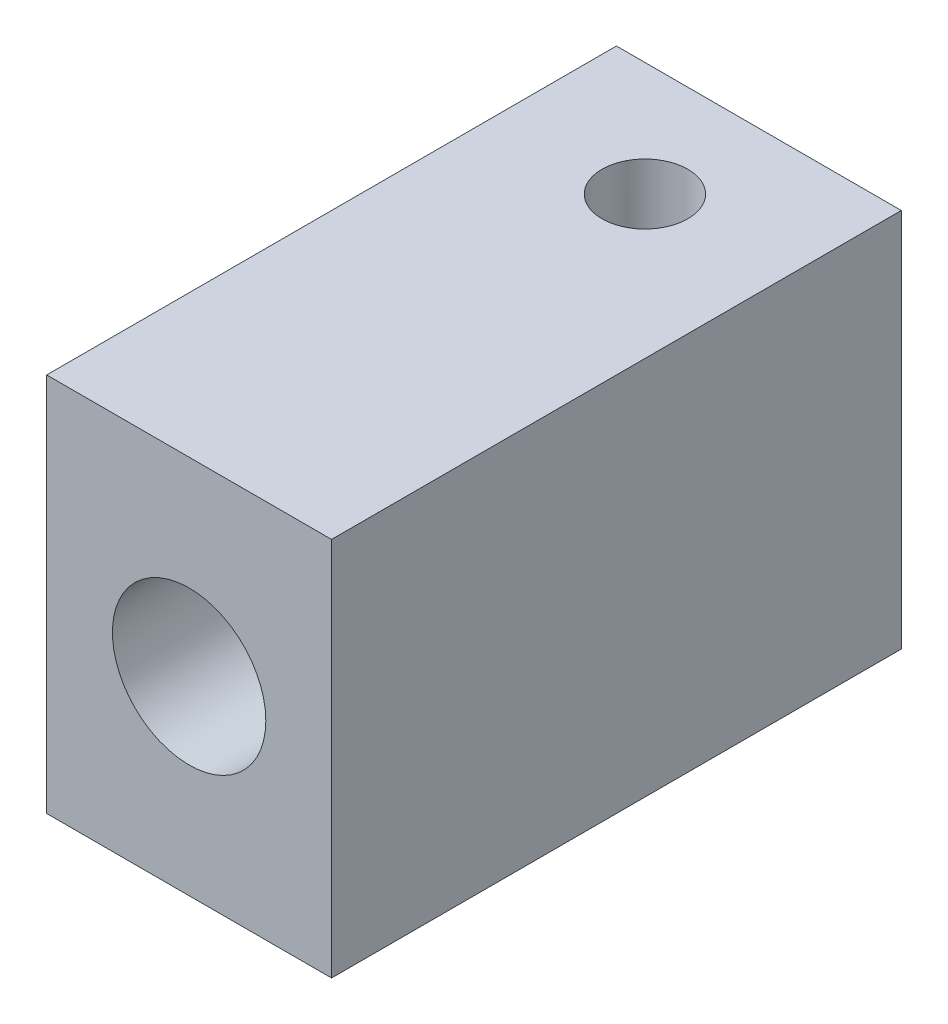
from build123d import *

# Parameters (mm, degrees)
SKETCH1_W                     = 7.5
SKETCH1_H                     = 10
BOSS_EXTRUDE1_DEPTH           = 15
HOLE_FOR_TUBING_R             = 1.1
CUT_EXTRUDE1_DEPTH            = 16
F_10_32_HOLE_FOR_LUER_SCREW_R = 2.0193
CUT_EXTRUDE2_DEPTH            = 7.5
F_4_40_SET_SCREW_HOLE_R       = 1.1303
CUT_EXTRUDE3_DEPTH            = 11


with BuildPart() as part:
    # Sketch1 → Boss-Extrude1 (new body)
    with BuildSketch(Plane.XY):
        with Locations((-4.663043478, 2.239130435)):
            Rectangle(SKETCH1_W, SKETCH1_H)
    extrude(amount=BOSS_EXTRUDE1_DEPTH)

    # hole for tubing → Cut-Extrude1 (cut, through all)
    with BuildSketch(Plane(origin=(0, 0, 0), x_dir=(-1, 0, 0), z_dir=(0, 0, -1))):
        with Locations((4.663043478, 2.239130435)):
            Circle(HOLE_FOR_TUBING_R)
    extrude(amount=-CUT_EXTRUDE1_DEPTH, mode=Mode.SUBTRACT)

    # 10-32 hole for luer screw → Cut-Extrude2 (cut)
    with BuildSketch(Plane.XY.offset(15)):
        with Locations((-4.663043478, 2.239130435)):
            Circle(F_10_32_HOLE_FOR_LUER_SCREW_R)
    extrude(amount=-CUT_EXTRUDE2_DEPTH, mode=Mode.SUBTRACT)

    # 4-40 set screw hole → Cut-Extrude3 (cut, through all)
    with BuildSketch(Plane(origin=(0, 7.239130435, 0), x_dir=(1, 0, 0), z_dir=(0, 1, 0))):
        with Locations((-4.663043478, -3)):
            Circle(F_4_40_SET_SCREW_HOLE_R)
    extrude(amount=-CUT_EXTRUDE3_DEPTH, mode=Mode.SUBTRACT)


solid = part.part
